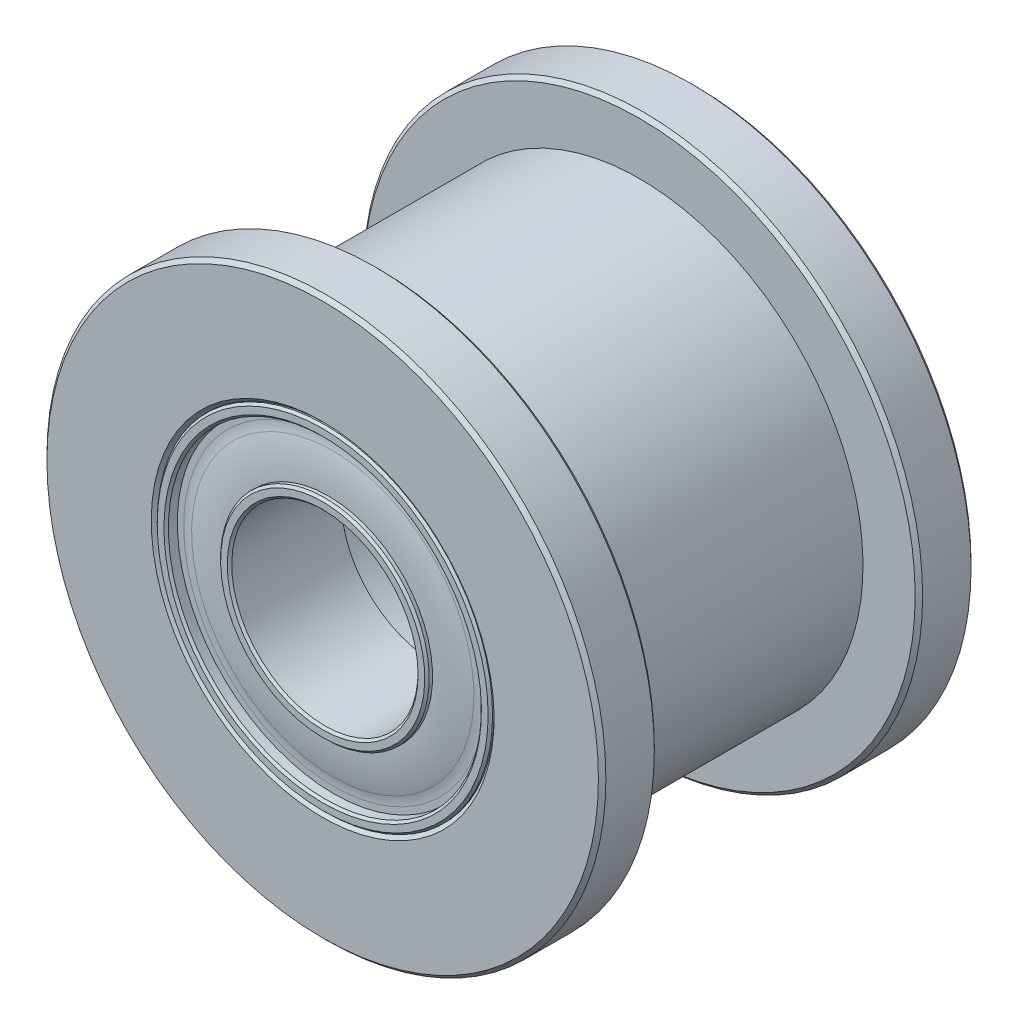
from build123d import *

# Parameters (mm, degrees)
CHAMFER2_SIZE = 0.06
FILLET2_R     = 1
CHAMFER1_SIZE = 0.1


with BuildPart() as part:
    # Sketch2 → Revolve1 (revolve)
    with BuildSketch(Plane(origin=(0, 0, 0), x_dir=(0, 0, -1), z_dir=(1, 0, 0))):
        with BuildLine():
            Line((5, 2.5), (2, 2.5))
            Line((2, 2.5), (2, 4.5))
            Line((2, 4.5), (5, 4.5))
            Line((5, 4.5), (5, 4.2))
            Line((5, 4.2), (4.7, 4.2))
            Line((4.7, 4.2), (4.7, 3.9))
            ThreePointArc((4.7, 3.9), (4.812327274, 3.355090083), (4.85, 2.8))
            Line((4.85, 2.8), (5, 2.8))
            Line((5, 2.8), (5, 2.5))
        make_face()
    revolve(axis=Axis((0, 0, 5), (0, 0, -1)))

    # Chamfer2
    chamfer2_edges = [part.edges().sort_by_distance(p)[0] for p in [
        (0, -2.5, -5),
        (0, -2.8, -5),
        (0, -4.2, -5),
        (0, -4.5, -5),
    ]]
    chamfer(chamfer2_edges, length=CHAMFER2_SIZE)

    # Fillet2
    fillet2_edges = [part.edges().sort_by_distance(p)[0] for p in [
        (0, -3.9, -4.7),
    ]]
    fillet(fillet2_edges, radius=FILLET2_R)


with BuildPart() as body_2:
    # Mirror1: mirrored copy
    add(part.part.mirror(Plane.XY))


with BuildPart() as body_3:
    # Sketch3 → Revolve2 (revolve)
    with BuildSketch(Plane(origin=(0, 0, 0), x_dir=(0, 0, -1), z_dir=(1, 0, 0))):
        Polygon((3.5, 7.5), (5, 7.5), (5, 4.5), (2, 4.5), (2, 3.5), (-2, 3.5), (-2, 4.5), (-5, 4.5), (-5, 7.5), (-3.5, 7.5), (-3.5, 6), (3.5, 6), align=None)
    revolve(axis=Axis((0, 0, 5), (0, 0, -1)))

    # Chamfer1
    chamfer1_edges = [body_3.edges().sort_by_distance(p)[0] for p in [
        (0, -4.5, 5),
        (0, -4.5, -5),
        (0, -7.5, -5),
        (0, -7.5, -3.5),
        (0, -7.5, 3.5),
        (0, -7.5, 5),
    ]]
    chamfer(chamfer1_edges, length=CHAMFER1_SIZE)


solid = Compound([part.part, body_2.part, body_3.part])
